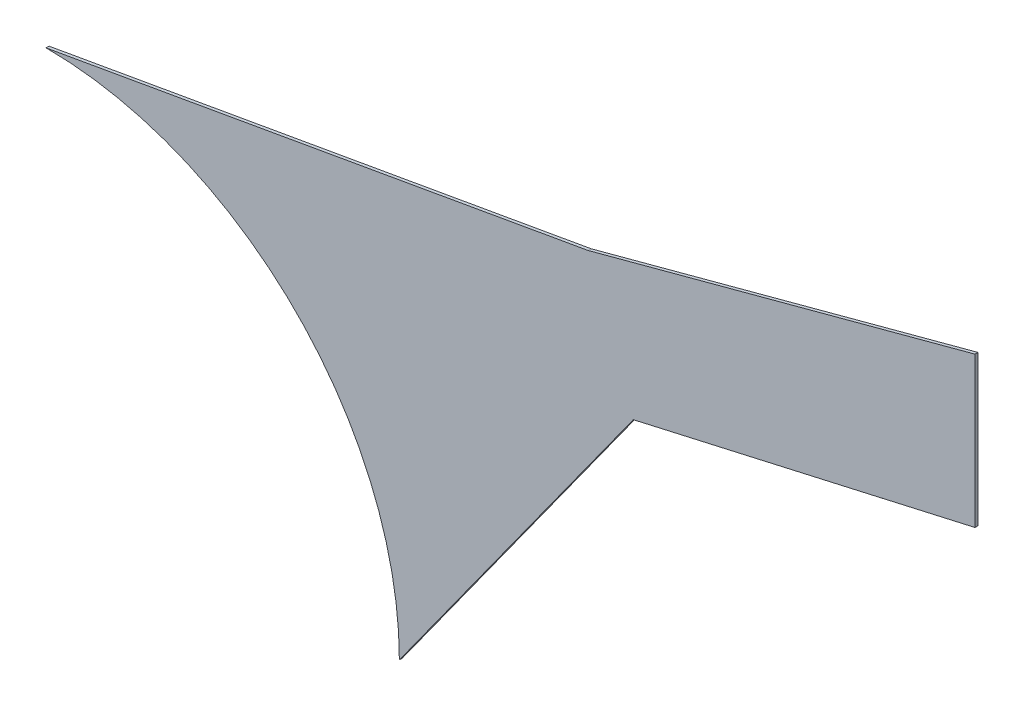
from build123d import *

# Parameters (mm, degrees)
BOSS_EXTRUDE1_DEPTH = 1.51892


with BuildPart() as part:
    # Sketch1 → Boss-Extrude1 (new body)
    with BuildSketch(Plane.XY):
        with BuildLine():
            Line((0, 179.31892), (275.155286192, 227.83622084))
            Line((275.155286192, 227.83622084), (471.431414094, 280.428250805))
            Line((471.431414094, 280.428250805), (471.431414094, 204.228250805))
            Line((471.431414094, 204.228250805), (298.031766742, 164.916645668))
            Line((298.031766742, 164.916645668), (179.31892, 0))
            ThreePointArc((179.31892, 0), (126.797624327, 126.797624327), (0, 179.31892))
        make_face()
    extrude(amount=BOSS_EXTRUDE1_DEPTH)


solid = part.part
